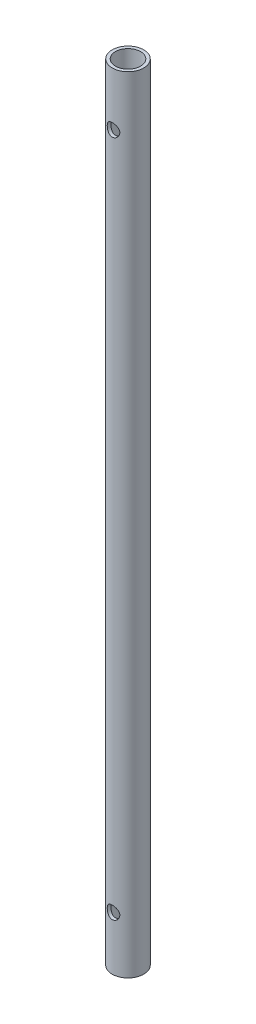
from build123d import *

# Parameters (mm, degrees)
SKETCH_1_R               = 5
SKETCH_1_R_2             = 4
EXTRUDE_1_DEPTH          = 124.5
SKETCH_2_R               = 2
CUT_EXTRUDE_1_DEPTH      = 6
CUT_EXTRUDE_1_DEPTH_BACK = 6


with BuildPart() as part:
    # 草图1 → 拉伸-薄壁1 (new body, symmetric)
    with BuildSketch(Plane(origin=(0, 0, 0), x_dir=(1, 0, 0), z_dir=(0, 1, 0))):
        Circle(SKETCH_1_R)
        Circle(SKETCH_1_R_2, mode=Mode.SUBTRACT)
    extrude(amount=EXTRUDE_1_DEPTH, both=True)

    # 草图2 → 切除-拉伸1 (cut, two sides)
    with BuildSketch(Plane.XY) as cut_extrude_1_sk:
        with Locations((0, -107.5)):
            Circle(SKETCH_2_R)
        with Locations((0, 107.5)):
            Circle(SKETCH_2_R)
    extrude(amount=CUT_EXTRUDE_1_DEPTH, mode=Mode.SUBTRACT)
    extrude(cut_extrude_1_sk.sketch, amount=-CUT_EXTRUDE_1_DEPTH_BACK, mode=Mode.SUBTRACT)


solid = part.part
